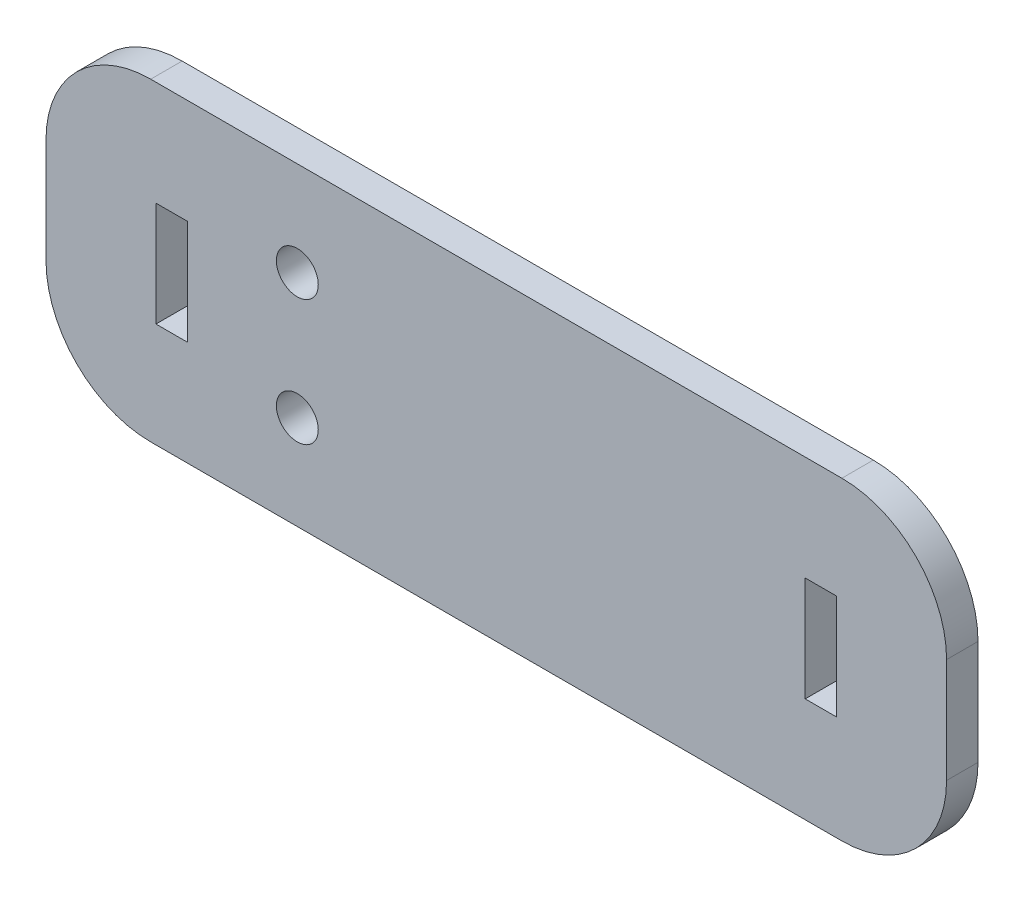
from build123d import *

# Parameters (mm, degrees)
CROQUIS1_W              = 86
CROQUIS1_H              = 30
SALIENTE_EXTRUIR1_DEPTH = 3
CORTAR_EXTRUIR1_REACH   = 5
CROQUIS2_R              = 2
CROQUIS2_W              = 3
CROQUIS2_H              = 10
REDONDEO1_R             = 10


with BuildPart() as part:
    # Croquis1 → Saliente-Extruir1 (new body)
    with BuildSketch(Plane.XY):
        Rectangle(CROQUIS1_W, CROQUIS1_H)
    extrude(amount=SALIENTE_EXTRUIR1_DEPTH)

    # Croquis2 → Cortar-Extruir1 (cut, up to next)
    with BuildSketch(Plane.XY.offset(3), mode=Mode.PRIVATE) as cortar_extruir1_sk1:
        with Locations((-19, 6)):
            Circle(CROQUIS2_R)
    cortar_extruir1_tool1 = extrude(cortar_extruir1_sk1.sketch, amount=-CORTAR_EXTRUIR1_REACH, mode=Mode.PRIVATE) & part.part
    add(cortar_extruir1_tool1.solids().sort_by_distance((-19, 6, 3))[0], mode=Mode.SUBTRACT)
    # Croquis2 → Cortar-Extruir1 (cut, up to next)
    with BuildSketch(Plane.XY.offset(3), mode=Mode.PRIVATE) as cortar_extruir1_sk2:
        with Locations((-19, -6)):
            Circle(CROQUIS2_R)
    cortar_extruir1_tool2 = extrude(cortar_extruir1_sk2.sketch, amount=-CORTAR_EXTRUIR1_REACH, mode=Mode.PRIVATE) & part.part
    add(cortar_extruir1_tool2.solids().sort_by_distance((-19, -6, 3))[0], mode=Mode.SUBTRACT)
    # Croquis2 → Cortar-Extruir1 (cut, up to next)
    with BuildSketch(Plane.XY.offset(3), mode=Mode.PRIVATE) as cortar_extruir1_sk3:
        with Locations((-31, 0)):
            Rectangle(CROQUIS2_W, CROQUIS2_H)
    cortar_extruir1_tool3 = extrude(cortar_extruir1_sk3.sketch, amount=-CORTAR_EXTRUIR1_REACH, mode=Mode.PRIVATE) & part.part
    add(cortar_extruir1_tool3.solids().sort_by_distance((-31, 0, 3))[0], mode=Mode.SUBTRACT)
    # Croquis2 → Cortar-Extruir1 (cut, up to next)
    with BuildSketch(Plane.XY.offset(3), mode=Mode.PRIVATE) as cortar_extruir1_sk4:
        with Locations((31, 0)):
            Rectangle(CROQUIS2_W, CROQUIS2_H)
    cortar_extruir1_tool4 = extrude(cortar_extruir1_sk4.sketch, amount=-CORTAR_EXTRUIR1_REACH, mode=Mode.PRIVATE) & part.part
    add(cortar_extruir1_tool4.solids().sort_by_distance((31, 0, 3))[0], mode=Mode.SUBTRACT)

    # Redondeo1
    redondeo1_edges = [part.edges().sort_by_distance(p)[0] for p in [
        (43, -15, 1.5),
        (-43, -15, 1.5),
        (-43, 15, 1.5),
        (43, 15, 1.5),
    ]]
    fillet(redondeo1_edges, radius=REDONDEO1_R)


solid = part.part
